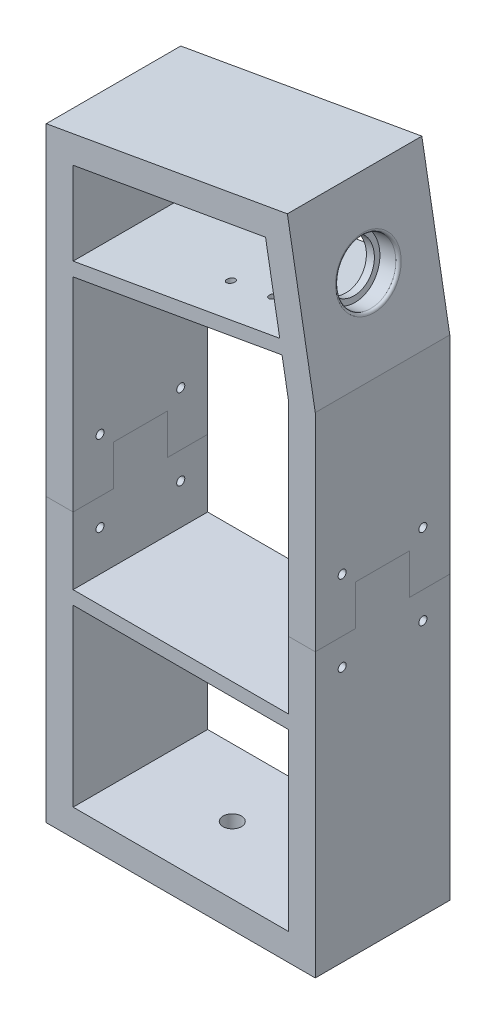
from build123d import *

# Parameters (mm, degrees)
BOSS_EXTRUDE1_DEPTH    = 50
SKETCH4_R              = 11.025
CUT_EXTRUDE1_DEPTH     = 7
SKETCH5_R              = 9
CUT_EXTRUDE2_DEPTH     = 7
BOSS_EXTRUDE2_DEPTH    = 50
SKETCH8_R              = 5
CUT_EXTRUDE3_DEPTH     = 10
CUT_EXTRUDE4_REACH     = 278.388
SKETCH9_R              = 1.485
SKETCH10_R             = 3.425
CUT_EXTRUDE5_DEPTH     = 10
SKETCH11_W             = 80
SKETCH11_H             = 5
BOSS_EXTRUDE3_DEPTH    = 50
FILLET1_R              = 1
SKETCH14_R             = 1.5
CUT_EXTRUDE6_DEPTH     = 266.502494397
SPLIT1_SURFACE_1_BACK  = 266.502
SPLIT1_SURFACE_1_DEPTH = 533.004
SPLIT1_SURFACE_2_BACK  = 266.502
SPLIT1_SURFACE_2_DEPTH = 533.004


with BuildPart() as part:
    # Sketch2 → Boss-Extrude1 (new body)
    with BuildSketch(Plane.XY):
        Polygon((-50, 225.01), (-50, 0), (50, 0), (50, 182.01), (39.631197958, 240.814398513), align=None)
        Polygon((-40, 216.619003688), (-40, 10), (40, 10), (40, 181.135113365), (31.519602204, 229.229839206), align=None, mode=Mode.SUBTRACT)
    extrude(amount=BOSS_EXTRUDE1_DEPTH)

    # Sketch4 → Cut-Extrude1 (cut)
    with BuildSketch(Plane(origin=(79.617858663, 14.038776629, 0), x_dir=(0, 0, -1), z_dir=(0.9848077530122079, 0.17364817766693136, 0))):
        with Locations(Location((-25, 200.891001389, 0), (0, 0, 90))):
            Circle(SKETCH4_R)
    extrude(amount=-CUT_EXTRUDE1_DEPTH, mode=Mode.SUBTRACT)

    # Sketch5 → Cut-Extrude2 (cut)
    with BuildSketch(Plane(origin=(72.724204392, 12.823239385, 0), x_dir=(0, 0, -1), z_dir=(0.9848077530122079, 0.17364817766693136, 0))):
        with Locations(Location((-25, 200.891001389, 0), (0, 0, 90))):
            Circle(SKETCH5_R)
    extrude(amount=-CUT_EXTRUDE2_DEPTH, mode=Mode.SUBTRACT)

    # Sketch7 → Boss-Extrude2 (add)
    with BuildSketch(Plane.XY.offset(50)):
        Polygon((36.795033842, 199.31137967), (37.66327473, 194.387340905), (-40, 180.69321016), (-40, 185.770343219), align=None)
    extrude(amount=-BOSS_EXTRUDE2_DEPTH)

    # Sketch8 → Cut-Extrude3 (cut)
    with BuildSketch(Plane.ZY.offset(50)):
        with Locations(Location((25, 204.163858422, 0), (0, 0, 270))):
            Circle(SKETCH8_R)
    extrude(amount=-CUT_EXTRUDE3_DEPTH, mode=Mode.SUBTRACT)

    # Sketch9 → Cut-Extrude4 (cut, up to next)
    with BuildSketch(Plane(origin=(123.233920299, 209.475754475, 0), x_dir=(-0.9848077530122079, -0.17364817766693152, 0), z_dir=(-0.17364817766693152, 0.9848077530122079, 0)), mode=Mode.PRIVATE) as cut_extrude4_sk1:
        with Locations((104.969193438, 15.4)):
            Circle(SKETCH9_R)
    cut_extrude4_tool1 = extrude(cut_extrude4_sk1.sketch, amount=CUT_EXTRUDE4_REACH, mode=Mode.PRIVATE) & part.part
    # Sketch9 → Cut-Extrude4 (cut, up to next)
    with BuildSketch(Plane(origin=(123.233920299, 209.475754475, 0), x_dir=(-0.9848077530122079, -0.17364817766693152, 0), z_dir=(-0.17364817766693152, 0.9848077530122079, 0)), mode=Mode.PRIVATE) as cut_extrude4_sk2:
        with Locations((104.969193438, 34.6)):
            Circle(SKETCH9_R)
    cut_extrude4_tool2 = extrude(cut_extrude4_sk2.sketch, amount=CUT_EXTRUDE4_REACH, mode=Mode.PRIVATE) & part.part
    # Sketch9 → Cut-Extrude4 (cut, up to next)
    with BuildSketch(Plane(origin=(123.233920299, 209.475754475, 0), x_dir=(-0.9848077530122079, -0.17364817766693152, 0), z_dir=(-0.17364817766693152, 0.9848077530122079, 0)), mode=Mode.PRIVATE) as cut_extrude4_sk3:
        with Locations(Location((120.969193438, 34.6, 0), (0, 0, 180))):
            Circle(SKETCH9_R)
    cut_extrude4_tool3 = extrude(cut_extrude4_sk3.sketch, amount=CUT_EXTRUDE4_REACH, mode=Mode.PRIVATE) & part.part
    # Sketch9 → Cut-Extrude4 (cut, up to next)
    with BuildSketch(Plane(origin=(123.233920299, 209.475754475, 0), x_dir=(-0.9848077530122079, -0.17364817766693152, 0), z_dir=(-0.17364817766693152, 0.9848077530122079, 0)), mode=Mode.PRIVATE) as cut_extrude4_sk4:
        with Locations(Location((120.969193438, 15.4, 0), (0, 0, 180))):
            Circle(SKETCH9_R)
    cut_extrude4_tool4 = extrude(cut_extrude4_sk4.sketch, amount=CUT_EXTRUDE4_REACH, mode=Mode.PRIVATE) & part.part
    add(cut_extrude4_tool1.solids().sort_by_distance((19.859445, 191.248045, 15.4))[0], mode=Mode.SUBTRACT)
    add(cut_extrude4_tool2.solids().sort_by_distance((19.859445, 191.248045, 34.6))[0], mode=Mode.SUBTRACT)
    add(cut_extrude4_tool3.solids().sort_by_distance((4.102521, 188.469674, 34.6))[0], mode=Mode.SUBTRACT)
    add(cut_extrude4_tool4.solids().sort_by_distance((4.102521, 188.469674, 15.4))[0], mode=Mode.SUBTRACT)

    # Sketch10 → Cut-Extrude5 (cut)
    with BuildSketch(Plane(origin=(0, 10, 0), x_dir=(1, 0, 0), z_dir=(0, 1, 0))):
        with Locations(Location((-5.851287133, -25, 0), (0, 0, 180))):
            Circle(SKETCH10_R)
        with Locations(Location((24.130974018, -25, 0), (0, 0, 180))):
            Circle(SKETCH10_R)
    extrude(amount=-CUT_EXTRUDE5_DEPTH, mode=Mode.SUBTRACT)

    # Sketch11 → Boss-Extrude3 (add)
    with BuildSketch(Plane.XY.offset(50)):
        with Locations((0, 77.5)):
            Rectangle(SKETCH11_W, SKETCH11_H)
    extrude(amount=-BOSS_EXTRUDE3_DEPTH)

    # Fillet1
    fillet1_edges = [part.edges().sort_by_distance(p)[0] for p in [
        (46.647973521, 201.020286829, 25),
    ]]
    fillet(fillet1_edges, radius=FILLET1_R)

    # Sketch14 → Cut-Extrude6 (cut, through all)
    with BuildSketch(Plane.ZY.offset(50)):
        with Locations(Location((40, 125, 0), (0, 0, 270))):
            Circle(SKETCH14_R)
        with Locations(Location((40, 95, 0), (0, 0, 270))):
            Circle(SKETCH14_R)
        with Locations((10, 95)):
            Circle(SKETCH14_R)
        with Locations((10, 125)):
            Circle(SKETCH14_R)
    extrude(amount=-CUT_EXTRUDE6_DEPTH, mode=Mode.SUBTRACT)


with BuildPart() as body_2:
    # Split1: the piece behind the surface
    add(part.part)
    # Split1 surface: a surface, the sketch's curves swept straight by 533.004 mm
    with BuildLine(Plane.ZY.offset(50).offset(-SPLIT1_SURFACE_1_BACK), mode=Mode.PRIVATE) as split1_surface_1_path:
        Line((0, 105), (15, 105))
        Line((15, 105), (15, 120))
        Line((15, 120), (35, 120))
        Line((35, 120), (35, 105))
        Line((35, 105), (50, 105))
    split1_surface_1 = Shell.extrude(split1_surface_1_path.wire(), (-1 * SPLIT1_SURFACE_1_DEPTH, 0 * SPLIT1_SURFACE_1_DEPTH, 0 * SPLIT1_SURFACE_1_DEPTH))
    split(bisect_by=split1_surface_1, keep=Keep.BOTTOM)


with BuildPart() as part_1:
    add(part.part)

    # Split1: split by a surface, the side it looks to stays
    # Split1 surface: a surface, the sketch's curves swept straight by 533.004 mm
    with BuildLine(Plane.ZY.offset(50).offset(-SPLIT1_SURFACE_2_BACK), mode=Mode.PRIVATE) as split1_surface_2_path:
        Line((0, 105), (15, 105))
        Line((15, 105), (15, 120))
        Line((15, 120), (35, 120))
        Line((35, 120), (35, 105))
        Line((35, 105), (50, 105))
    split1_surface_2 = Shell.extrude(split1_surface_2_path.wire(), (-1 * SPLIT1_SURFACE_2_DEPTH, 0 * SPLIT1_SURFACE_2_DEPTH, 0 * SPLIT1_SURFACE_2_DEPTH))
    split(bisect_by=split1_surface_2, keep=Keep.TOP)


solid = Compound([body_2.part, part_1.part])
